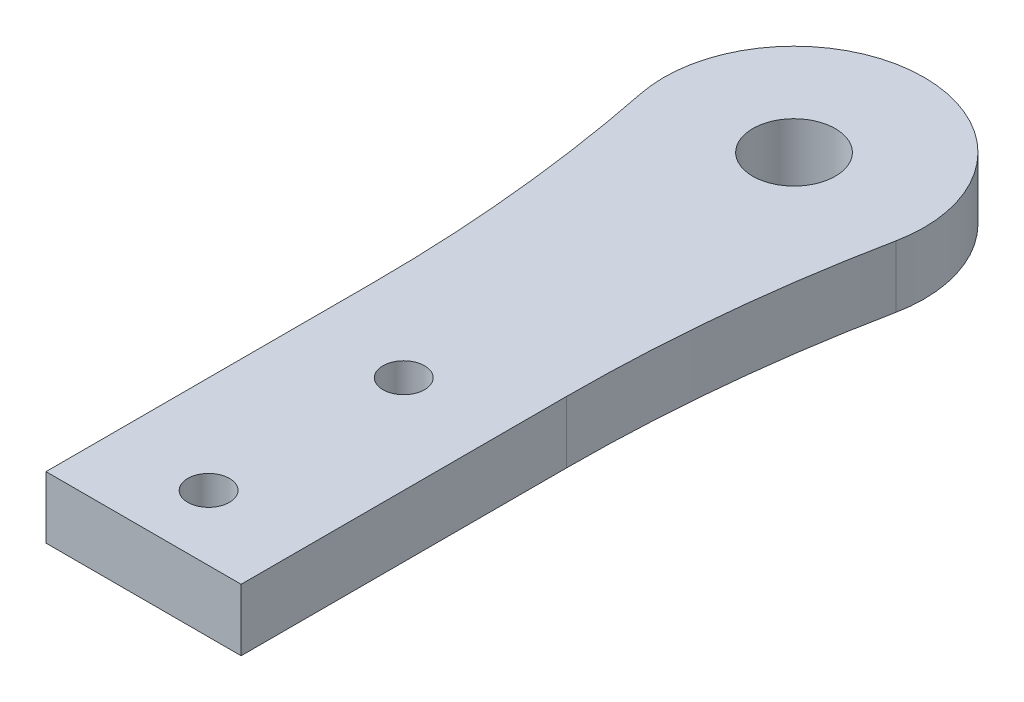
from build123d import *

# Parameters (mm, degrees)
SKETCH1_R           = 3.175
SKETCH1_R_2         = 1.6
BOSS_EXTRUDE1_DEPTH = 4.7625


with BuildPart() as part:
    # Sketch1 → Boss-Extrude1 (new body)
    with BuildSketch(Plane(origin=(0, 0, 0), x_dir=(1, 0, 0), z_dir=(0, 1, 0))):
        with BuildLine():
            Line((-7.5, 0), (7.5, 0))
            Line((7.5, 0), (7.5, 25))
            ThreePointArc((7.5, 25), (8.076926638, 36.567307336), (9.801980198, 48.01980198))
            ThreePointArc((9.801980198, 48.01980198), (0, 60), (-9.801980198, 48.01980198))
            ThreePointArc((-9.801980198, 48.01980198), (-8.076926638, 36.567307336), (-7.5, 25))
            Line((-7.5, 25), (-7.5, 0))
        make_face()
        with Locations((0, 50)):
            Circle(SKETCH1_R, mode=Mode.SUBTRACT)
        with Locations((0, 5)):
            Circle(SKETCH1_R_2, mode=Mode.SUBTRACT)
        with Locations((0, 20)):
            Circle(SKETCH1_R_2, mode=Mode.SUBTRACT)
    extrude(amount=BOSS_EXTRUDE1_DEPTH)


solid = part.part
